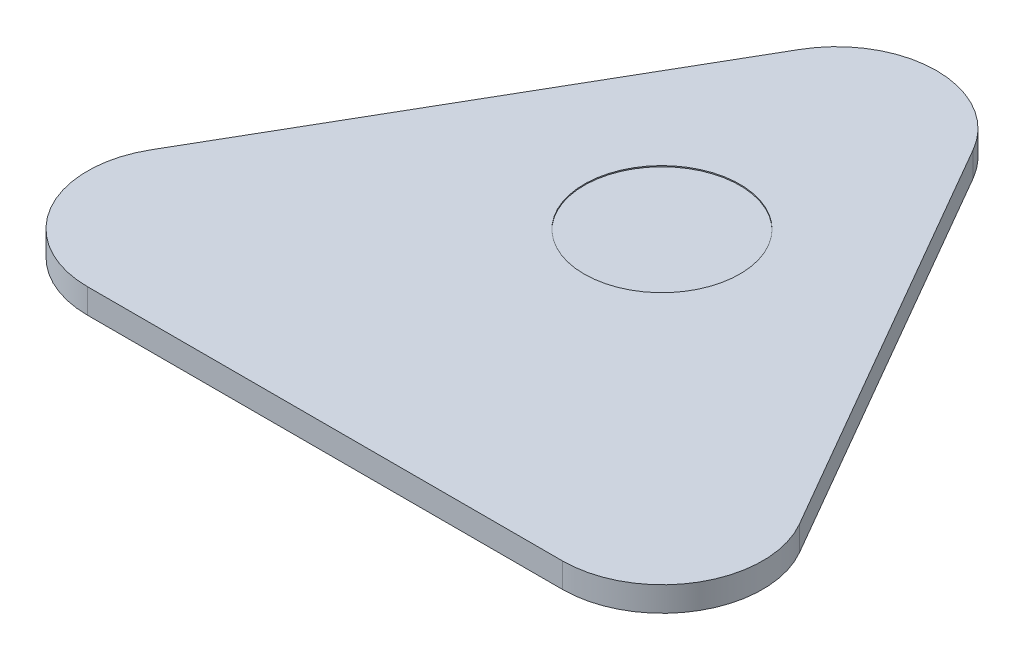
from build123d import *

# Parameters (mm, degrees)
BOSS_EXTRUDE1_DEPTH = 2.38125
SKETCH2_R           = 7.5
CUT_EXTRUDE1_DEPTH  = 0.1


with BuildPart() as part:
    # Sketch1 → Boss-Extrude1 (new body)
    with BuildSketch(Plane(origin=(0, 0, 0), x_dir=(1, 0, 0), z_dir=(0, 1, 0))):
        with BuildLine():
            Line((-8.357145147, 31.238774815), (-31.232145147, -8.381887408))
            ThreePointArc((-31.232145147, -8.381887408), (-31.232145147, -18.031887408), (-22.875, -22.856887408))
            Line((-22.875, -22.856887408), (22.875, -22.856887408))
            ThreePointArc((22.875, -22.856887408), (31.232145147, -18.031887408), (31.232145147, -8.381887408))
            Line((31.232145147, -8.381887408), (8.357145147, 31.238774815))
            ThreePointArc((8.357145147, 31.238774815), (0, 36.063774815), (-8.357145147, 31.238774815))
        make_face()
    extrude(amount=BOSS_EXTRUDE1_DEPTH)

    # Sketch2 → Cut-Extrude1 (cut)
    with BuildSketch(Plane(origin=(0, 2.38125, 0), x_dir=(1, 0, 0), z_dir=(0, 1, 0))):
        with Locations((0, 9.613774815)):
            Circle(SKETCH2_R)
    extrude(amount=-CUT_EXTRUDE1_DEPTH, mode=Mode.SUBTRACT)


solid = part.part
